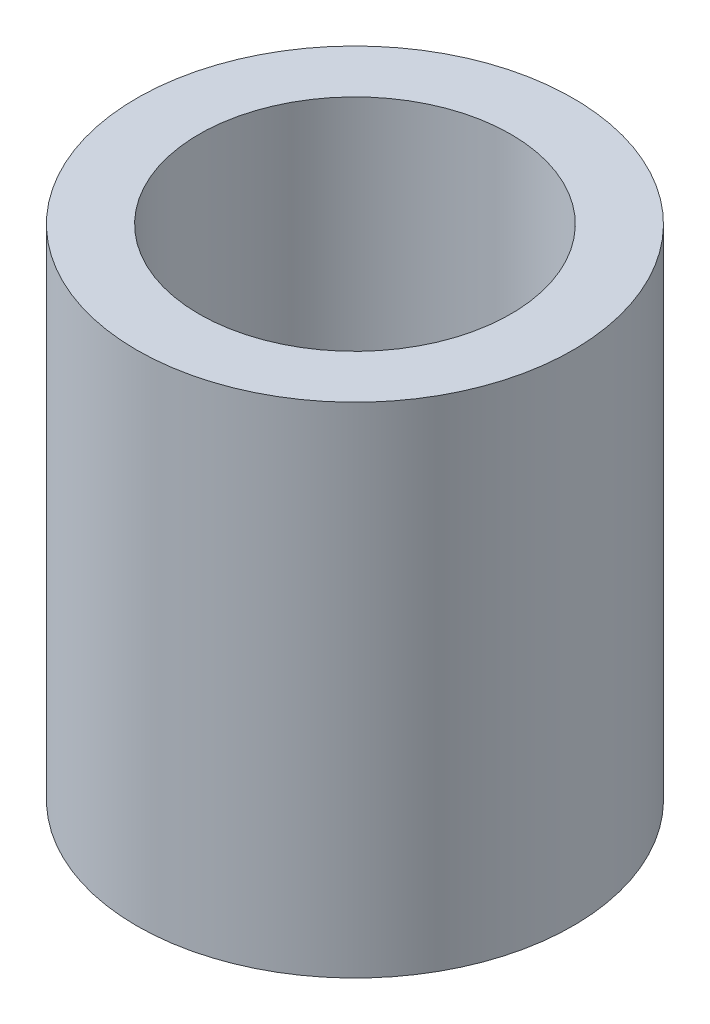
from build123d import *

# Parameters (mm, degrees)
SKETCH1_R           = 11.1125
SKETCH1_R_2         = 7.9375
BOSS_EXTRUDE1_DEPTH = 25.4


with BuildPart() as part:
    # Sketch1 → Boss-Extrude1 (new body)
    with BuildSketch(Plane(origin=(0, 0, 0), x_dir=(1, 0, 0), z_dir=(0, 1, 0))):
        Circle(SKETCH1_R)
        Circle(SKETCH1_R_2, mode=Mode.SUBTRACT)
    extrude(amount=BOSS_EXTRUDE1_DEPTH)


solid = part.part
